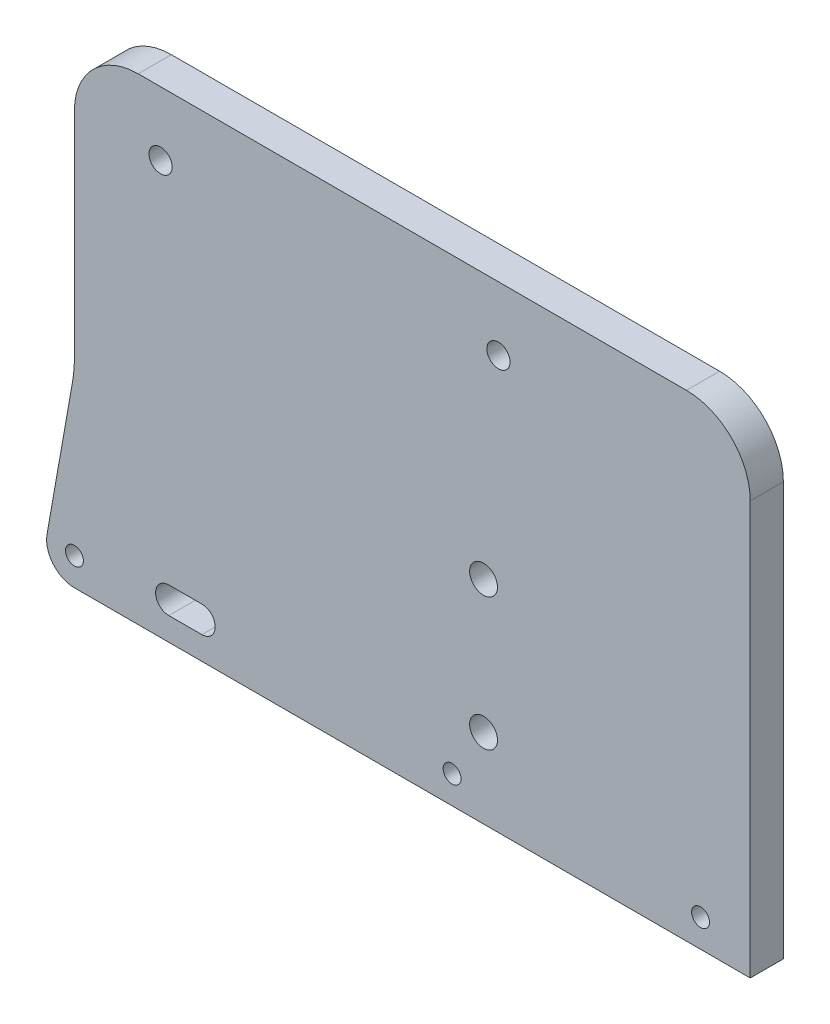
from build123d import *

# Parameters (mm, degrees)
SKETCH1_R           = 2.1
SKETCH1_R_2         = 1.75
SKETCH1_R_3         = 1.35
BOSS_EXTRUDE1_DEPTH = 5


with BuildPart() as part:
    # Sketch1 → Boss-Extrude1 (new body)
    with BuildSketch(Plane.XY):
        with BuildLine():
            Line((-62.05384494, 14.663645746), (-65.886192563, -7.070677654))
            ThreePointArc((-65.886192563, -7.070677654), (-64.967386661, -10.499707961), (-61.75, -12))
            Line((-61.75, -12), (40.25, -12))
            Line((40.25, -12), (40.25, 50.37))
            ThreePointArc((40.25, 50.37), (37.429438303, 57.179438303), (30.62, 60))
            Line((30.62, 60), (-52.12, 60))
            ThreePointArc((-52.12, 60), (-58.929438303, 57.179438303), (-61.75, 50.37))
            Line((-61.75, 50.37), (-61.75, 18.1366093))
            ThreePointArc((-61.75, 18.1366093), (-61.826106038, 16.393494445), (-62.05384494, 14.663645746))
        make_face()
        Circle(SKETCH1_R, mode=Mode.SUBTRACT)
        with Locations((-48.75, 50.37)):
            Circle(SKETCH1_R_2, mode=Mode.SUBTRACT)
        with Locations((32.75, -7.8)):
            Circle(SKETCH1_R_3, mode=Mode.SUBTRACT)
        with Locations((2.25, 50.37)):
            Circle(SKETCH1_R_2, mode=Mode.SUBTRACT)
        with Locations((-61.75, -7.8)):
            Circle(SKETCH1_R_3, mode=Mode.SUBTRACT)
        with Locations((-4.75, -7.8)):
            Circle(SKETCH1_R_3, mode=Mode.SUBTRACT)
        with Locations((0, 20)):
            Circle(SKETCH1_R, mode=Mode.SUBTRACT)
        with BuildLine():
            Line((-47.5, -4.5), (-42.5, -4.5))
            ThreePointArc((-42.5, -4.5), (-40.5, -6.5), (-42.5, -8.5))
            Line((-42.5, -8.5), (-47.5, -8.5))
            ThreePointArc((-47.5, -8.5), (-49.5, -6.5), (-47.5, -4.5))
        make_face(mode=Mode.SUBTRACT)
    extrude(amount=BOSS_EXTRUDE1_DEPTH)


solid = part.part
